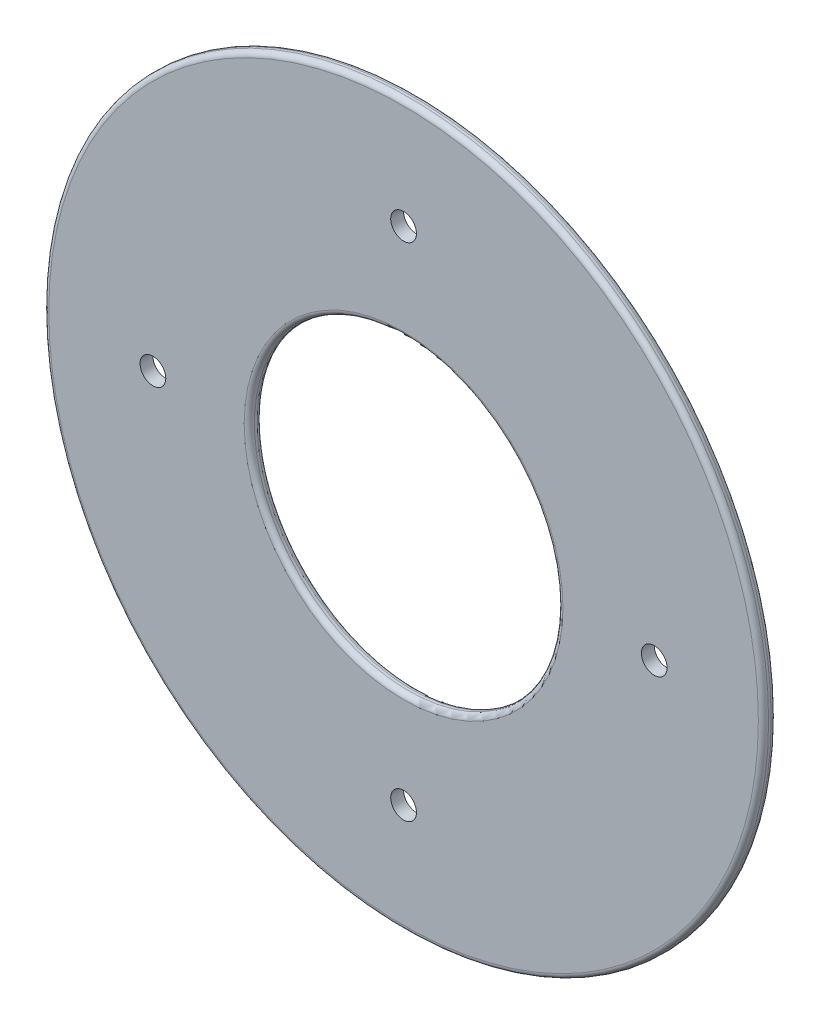
from build123d import *

# Parameters (mm, degrees)
SKETCH1_R           = 88.9
BOSS_EXTRUDE1_DEPTH = 3.175
FILLET1_R           = 1.27
SKETCH2_R           = 38.1
SKETCH2_R_2         = 3.175
CUT_EXTRUDE1_DEPTH  = 12.7
FILLET2_R           = 1.27


with BuildPart() as part:
    # Sketch1 → Boss-Extrude1 (new body)
    with BuildSketch(Plane.XY):
        Circle(SKETCH1_R)
    extrude(amount=BOSS_EXTRUDE1_DEPTH)

    # Fillet1
    fillet1_edges = [part.edges().sort_by_distance(p)[0] for p in [
        (-88.9, 0, 0),
        (-88.9, 0, 3.175),
    ]]
    fillet(fillet1_edges, radius=FILLET1_R)

    # Sketch2 → Cut-Extrude1 (cut)
    with BuildSketch(Plane.XY.offset(3.175)):
        Circle(SKETCH2_R)
        with Locations((0, 61.9125)):
            Circle(SKETCH2_R_2)
        with Locations((61.9125, 0)):
            Circle(SKETCH2_R_2)
        with Locations((0, -61.9125)):
            Circle(SKETCH2_R_2)
        with Locations((-61.9125, 0)):
            Circle(SKETCH2_R_2)
    extrude(amount=-CUT_EXTRUDE1_DEPTH, mode=Mode.SUBTRACT)

    # Fillet2
    fillet2_edges = [part.edges().sort_by_distance(p)[0] for p in [
        (-38.1, 0, 0),
        (-38.1, 0, 3.175),
    ]]
    fillet(fillet2_edges, radius=FILLET2_R)


solid = part.part
